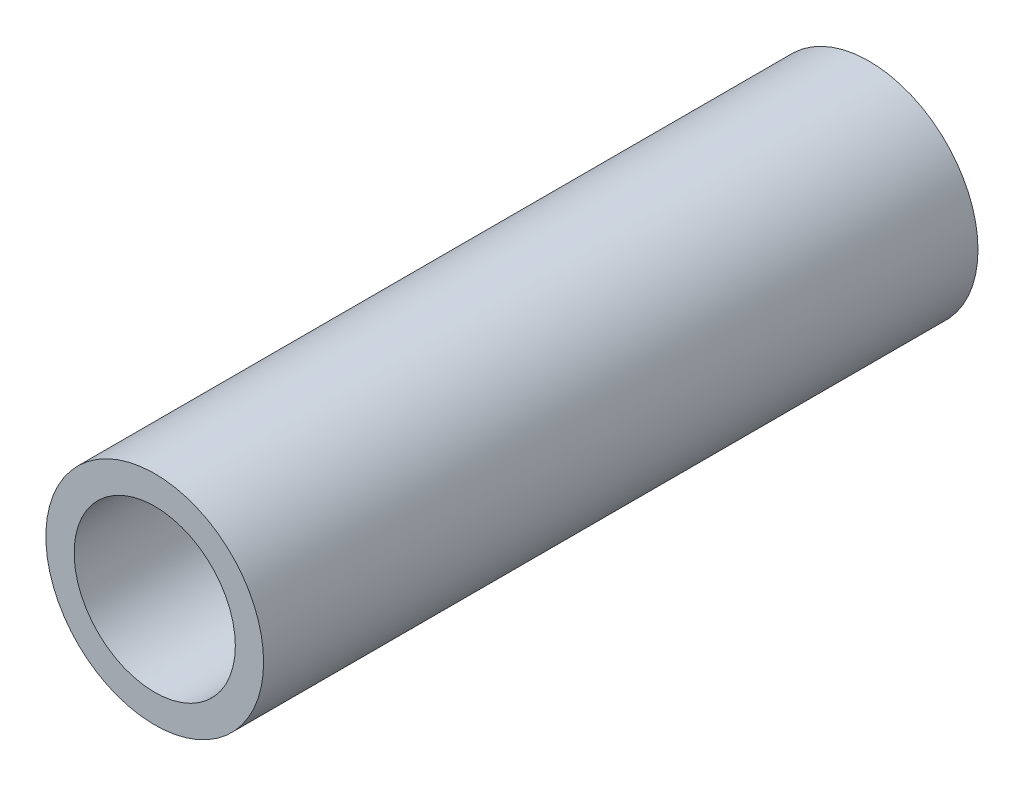
from build123d import *

# Parameters (mm, degrees)
SKETCH1_R           = 10.668
SKETCH1_R_2         = 7.8994
EXTRUDE_THIN1_DEPTH = 35


with BuildPart() as part:
    # Sketch1 → Extrude-Thin1 (new body, symmetric)
    with BuildSketch(Plane.XY):
        Circle(SKETCH1_R)
        Circle(SKETCH1_R_2, mode=Mode.SUBTRACT)
    extrude(amount=EXTRUDE_THIN1_DEPTH, both=True)


solid = part.part
